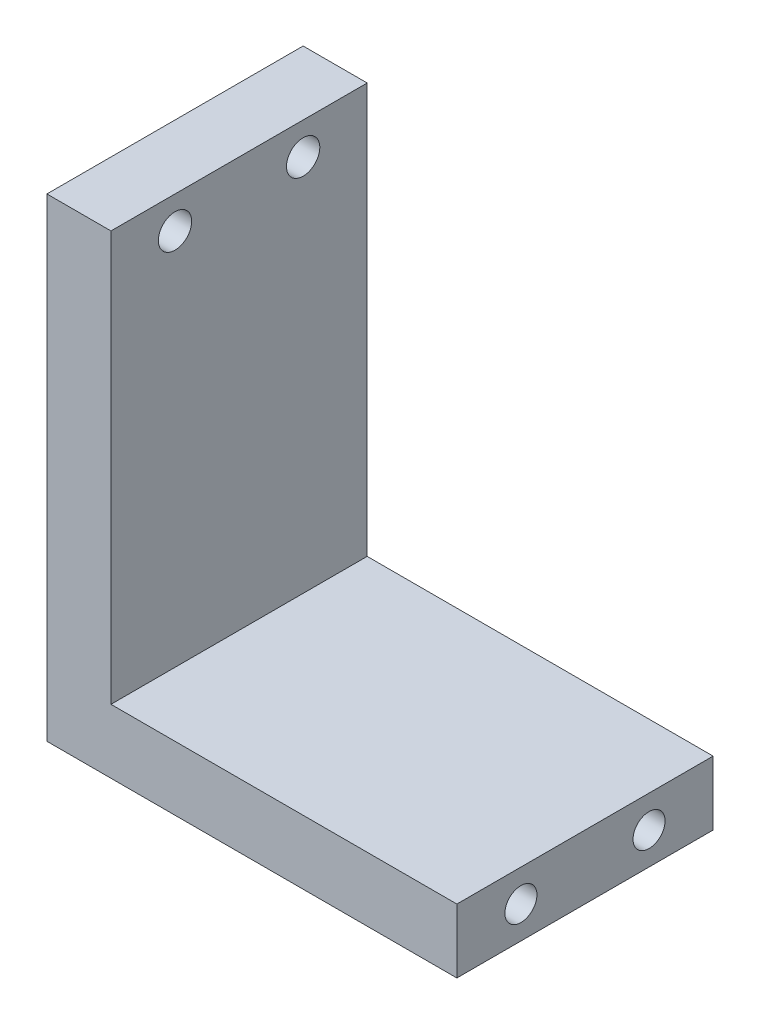
from build123d import *

# Parameters (mm, degrees)
BOSS_EXTRUDE_EQUERRE_DEPTH                     = 20
FRAISAGE_POUR_VIS_T_TE_FRAIS_E_M21_D           = 2.6
FRAISAGE_POUR_VIS_T_TE_FRAIS_E_M21_CSINK_D     = 4.4
FRAISAGE_POUR_VIS_T_TE_FRAIS_E_M21_CSINK_ANGLE = 90
TROU_TARAUD_M3X0_51_D                          = 2.5
TROU_TARAUD_M3X0_51_DEPTH                      = 10
TROU_TARAUD_M3X0_51_TIP                        = 0.751075774


with BuildPart() as part:
    # Esquisse1 → Boss_Extrude_Equerre (new body)
    with BuildSketch(Plane(origin=(0, 0, 0), x_dir=(0, 1, 0), z_dir=(0, 0, 1))):
        Polygon((0, 0), (32, 0), (32, 5), (-5, 5), (-5, 0), (-5, -27), (0, -27), align=None)
    extrude(amount=BOSS_EXTRUDE_EQUERRE_DEPTH)

    # Fraisage pour vis à tête fraisée M21 (through all)
    with Locations(Plane.ZY.offset(5)):
        with Locations((15, 29.5), (5, 29.5)):
            CounterSinkHole(FRAISAGE_POUR_VIS_T_TE_FRAIS_E_M21_D / 2, FRAISAGE_POUR_VIS_T_TE_FRAIS_E_M21_CSINK_D / 2, counter_sink_angle=FRAISAGE_POUR_VIS_T_TE_FRAIS_E_M21_CSINK_ANGLE)

    # Trou taraudé M3x0.51
    with Locations(Plane.YZ.offset(27)):
        with Locations((-2.5, 15), (-2.5, 5)):
            Hole(TROU_TARAUD_M3X0_51_D / 2, depth=TROU_TARAUD_M3X0_51_DEPTH)
            with Locations((0, 0, -(TROU_TARAUD_M3X0_51_DEPTH + TROU_TARAUD_M3X0_51_TIP / 2))):  # 118° drill point
                Cone(0, TROU_TARAUD_M3X0_51_D / 2, TROU_TARAUD_M3X0_51_TIP, mode=Mode.SUBTRACT)


solid = part.part
